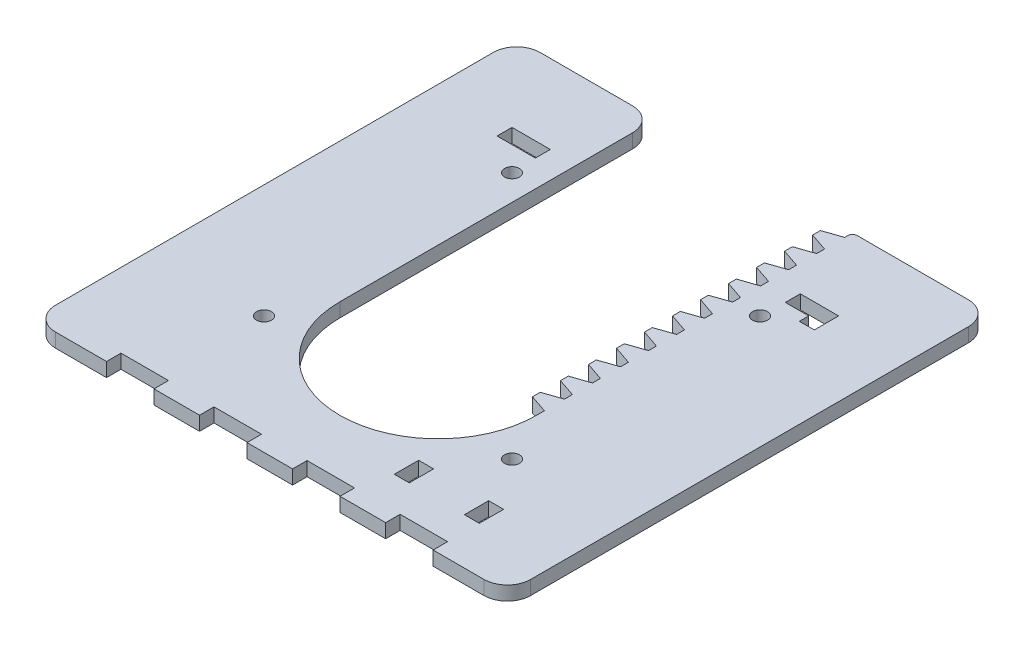
from build123d import *

# Parameters (mm, degrees)
SKETCH1_R           = 1.6
BOSS_EXTRUDE1_DEPTH = 3
SKETCH6_W           = 10.163490601
SKETCH6_H           = 3.2
SKETCH6_W_2         = 8.2
SKETCH6_W_3         = 3.2
SKETCH6_H_2         = 5.2
CUT_EXTRUDE4_DEPTH  = 4


with BuildPart() as part:
    # Sketch1 → Boss-Extrude1 (new body)
    with BuildSketch(Plane(origin=(0, 0, 0), x_dir=(1, 0, 0), z_dir=(0, 1, 0))):
        with BuildLine():
            Line((21.058452488, 3.842990858), (17.188733854, 5.16651258))
            Line((17.188733854, 5.16651258), (17.188733854, 6.83348742))
            Line((17.188733854, 6.83348742), (21.058452488, 8.157009142))
            Line((21.058452488, 8.157009142), (21.058452488, 9.842990858))
            Line((21.058452488, 9.842990858), (17.188733854, 11.16651258))
            Line((17.188733854, 11.16651258), (17.188733854, 12.83348742))
            Line((17.188733854, 12.83348742), (21.058452488, 14.157009142))
            Line((21.058452488, 14.157009142), (21.058452488, 15.842990858))
            Line((21.058452488, 15.842990858), (17.188733854, 17.16651258))
            Line((17.188733854, 17.16651258), (17.188733854, 18.83348742))
            Line((17.188733854, 18.83348742), (21.058452488, 20.157009142))
            Line((21.058452488, 20.157009142), (21.058452488, 21.842990858))
            Line((21.058452488, 21.842990858), (17.188733854, 23.16651258))
            Line((17.188733854, 23.16651258), (17.188733854, 24.83348742))
            Line((17.188733854, 24.83348742), (21.058452488, 26.157009142))
            Line((21.058452488, 26.157009142), (21.058452488, 27.842990858))
            Line((21.058452488, 27.842990858), (17.188733854, 29.16651258))
            Line((17.188733854, 29.16651258), (17.188733854, 30.83348742))
            Line((17.188733854, 30.83348742), (21.058452488, 32.157009142))
            Line((21.058452488, 32.157009142), (21.058452488, 33.842990858))
            Line((21.058452488, 33.842990858), (17.188733854, 35.16651258))
            Line((17.188733854, 35.16651258), (17.188733854, 36.83348742))
            Line((17.188733854, 36.83348742), (21.058452488, 38.157009142))
            Line((21.058452488, 38.157009142), (21.058452488, 39.842990858))
            Line((21.058452488, 39.842990858), (17.188733854, 41.16651258))
            Line((17.188733854, 41.16651258), (17.188733854, 42.83348742))
            Line((17.188733854, 42.83348742), (21.058452488, 44.157009142))
            Line((21.058452488, 44.157009142), (21.058452488, 45.842990858))
            Line((21.058452488, 45.842990858), (17.188733854, 47.16651258))
            Line((17.188733854, 47.16651258), (17.188733854, 48.83348742))
            Line((17.188733854, 48.83348742), (21.058452488, 50.157009142))
            Line((21.058452488, 50.157009142), (21.058452488, 51.842990858))
            Line((21.058452488, 51.842990858), (17.188733854, 53.16651258))
            Line((17.188733854, 53.16651258), (17.188733854, 54.83348742))
            Line((17.188733854, 54.83348742), (21.058452488, 56.157009142))
            Line((21.058452488, 56.157009142), (21.058452488, 57.842990858))
            Line((21.058452488, 57.842990858), (17.188733854, 59.16651258))
            Line((17.188733854, 59.16651258), (17.188733854, 60.83348742))
            Line((17.188733854, 60.83348742), (21.058452488, 62.157009142))
            Line((21.058452488, 62.157009142), (21.058452488, 62.842990858))
            ThreePointArc((21.058452488, 62.842990858), (21.351345707, 63.550097639), (22.058452488, 63.842990858))
            Line((22.058452488, 63.842990858), (45.872217102, 63.842990858))
            ThreePointArc((45.872217102, 63.842990858), (49.407751008, 62.378524764), (50.872217102, 58.842990858))
            Line((50.872217102, 58.842990858), (50.872217102, -34.901443346))
            ThreePointArc((50.872217102, -34.901443346), (49.407751008, -38.436977252), (45.872217102, -39.901443346))
            Line((45.872217102, -39.901443346), (-45.872217102, -39.901443346))
            ThreePointArc((-45.872217102, -39.901443346), (-49.407751008, -38.436977252), (-50.872217102, -34.901443346))
            Line((-50.872217102, -34.901443346), (-50.872217102, 58.842990858))
            ThreePointArc((-50.872217102, 58.842990858), (-49.407751008, 62.378524764), (-45.872217102, 63.842990858))
            Line((-45.872217102, 63.842990858), (-26.058452488, 63.842990858))
            ThreePointArc((-26.058452488, 63.842990858), (-22.522918582, 62.378524764), (-21.058452488, 58.842990858))
            Line((-21.058452488, 58.842990858), (-21.058452488, -3.842990858))
            ThreePointArc((-21.058452488, -3.842990858), (0, -24.901443346), (21.058452488, -3.842990858))
            Line((21.058452488, -3.842990858), (21.058452488, -2.157009142))
            Line((21.058452488, -2.157009142), (17.188733854, -0.83348742))
            Line((17.188733854, -0.83348742), (17.188733854, 0.83348742))
            Line((17.188733854, 0.83348742), (21.058452488, 2.157009142))
            Line((21.058452488, 2.157009142), (21.058452488, 3.842990858))
        make_face()
        with Locations((26.558452488, -14.587678732)):
            Circle(SKETCH1_R, mode=Mode.SUBTRACT)
        with Locations((-26.558452488, -14.587678732)):
            Circle(SKETCH1_R, mode=Mode.SUBTRACT)
        with Locations((-26.558452488, 38.529226244)):
            Circle(SKETCH1_R, mode=Mode.SUBTRACT)
        with Locations((26.558452488, 38.529226244)):
            Circle(SKETCH1_R, mode=Mode.SUBTRACT)
    extrude(amount=BOSS_EXTRUDE1_DEPTH)

    # Sketch6 → Cut-Extrude4 (cut, through all)
    with BuildSketch(Plane(origin=(0, 0, 0), x_dir=(1, 0, 0), z_dir=(0, 1, 0))):
        with Locations((9.963490601, -38.401443346)):
            Rectangle(SKETCH6_W, SKETCH6_H)
        with Locations((29.890471802, -38.401443346)):
            Rectangle(SKETCH6_W, SKETCH6_H)
        with Locations((-29.890471802, -38.401443346)):
            Rectangle(SKETCH6_W, SKETCH6_H)
        with Locations((-9.963490601, -38.401443346)):
            Rectangle(SKETCH6_W, SKETCH6_H)
        with Locations((-30.872217102, 45.342990858)):
            Rectangle(SKETCH6_W_2, SKETCH6_H)
        with Locations((33.372217102, -27.401443346)):
            Rectangle(SKETCH6_W_3, SKETCH6_H_2)
        Polygon((34.972217102, 41.742990858), (34.972217102, 46.942990858), (26.772217102, 46.942990858), (26.772217102, 43.742990858), (31.772217102, 43.742990858), (31.772217102, 41.742990858), align=None)
        with Locations((18.372217102, -27.401443346)):
            Rectangle(SKETCH6_W_3, SKETCH6_H_2)
    extrude(amount=CUT_EXTRUDE4_DEPTH, mode=Mode.SUBTRACT)


solid = part.part
